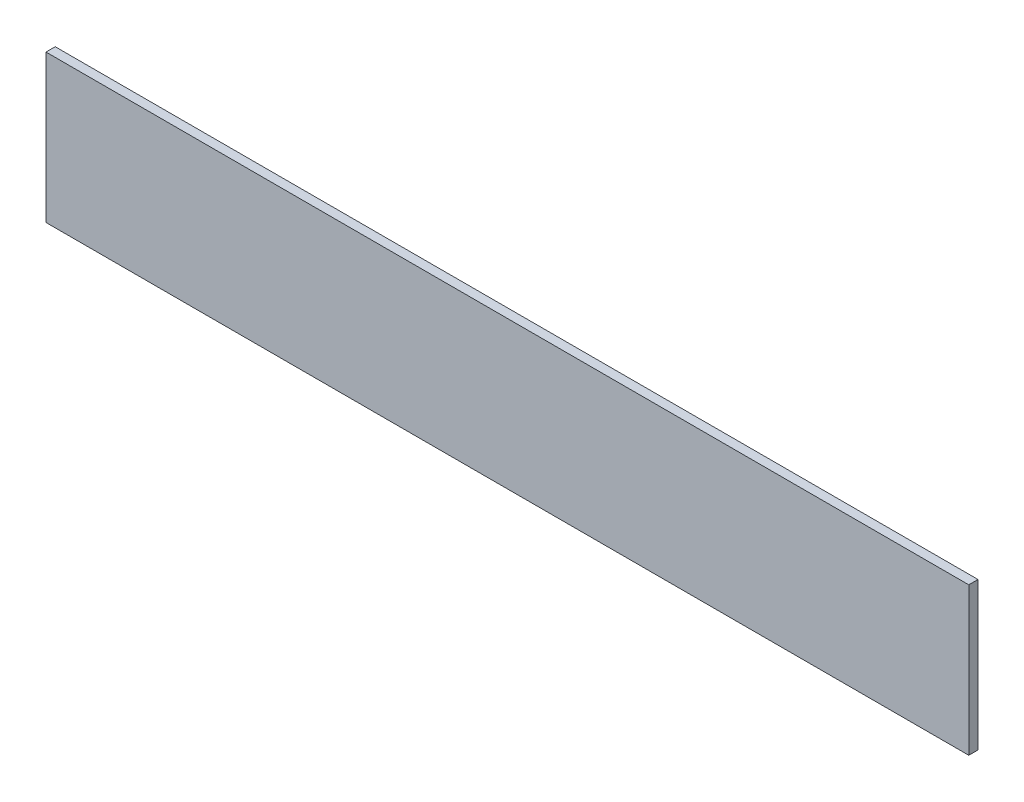
from build123d import *

# Parameters (mm, degrees)
SKETCH1_W           = 1270
SKETCH1_H           = 203.2
BOSS_EXTRUDE1_DEPTH = 12.7


with BuildPart() as part:
    # Sketch1 → Boss-Extrude1 (new body)
    with BuildSketch(Plane.XY):
        Rectangle(SKETCH1_W, SKETCH1_H)
    extrude(amount=BOSS_EXTRUDE1_DEPTH)


solid = part.part
